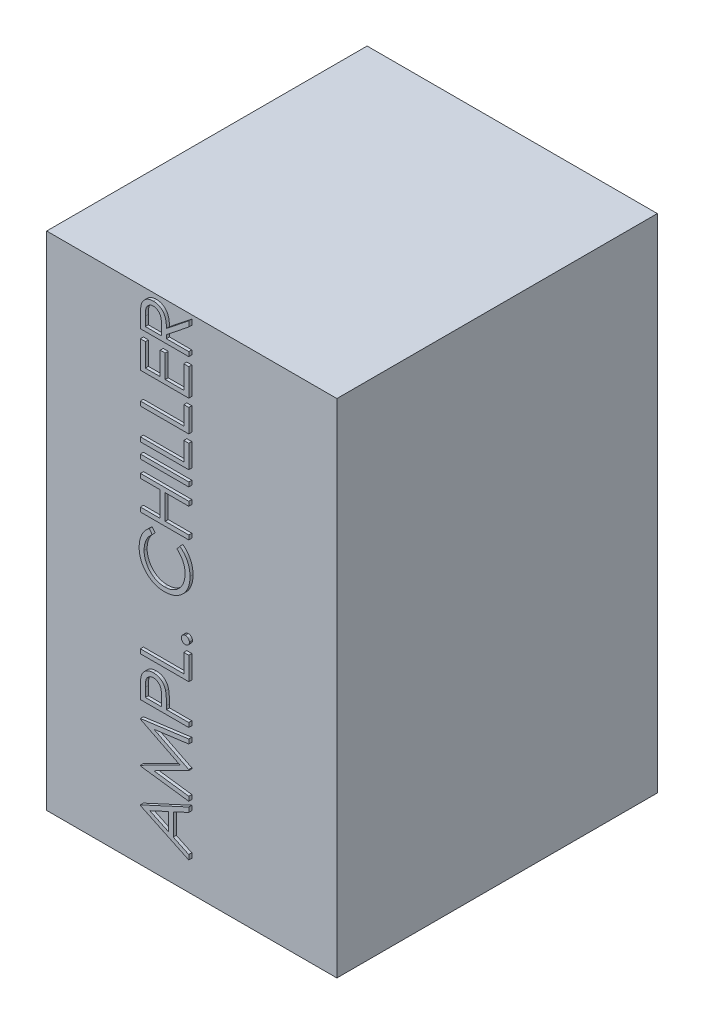
from build123d import *

# Parameters (mm, degrees)
SKETCH1_W           = 480
SKETCH1_H           = 830
BOSS_EXTRUDE1_DEPTH = 530
SKETCH2_W           = 80
SKETCH2_H           = 7.17948718
BOSS_EXTRUDE2_DEPTH = 5


with BuildPart() as part:
    # Sketch1 → Boss-Extrude1 (new body)
    with BuildSketch(Plane.XY):
        with Locations((-240, -415)):
            Rectangle(SKETCH1_W, SKETCH1_H)
    extrude(amount=BOSS_EXTRUDE1_DEPTH)

    # Sketch2 → Boss-Extrude2 (add)
    with BuildSketch(Plane.XY.offset(530)):
        with BuildLine():
            Line((-320, -57.435897436), (-320, -41.426282051))
            add(Edge.make_bspline(
                [(-320, -41.426282051), (-319.996443749, -40.3579134), (-319.989615353, -38.306527242), (-319.951540772, -35.367709633), (-319.842412641, -32.697375988), (-319.748502162, -30.296922518), (-319.577257789, -28.166393261), (-319.413585855, -26.299255187), (-319.199330751, -24.704107815), (-319.000349655, -23.738488357), (-318.91025641, -23.301282051)],
                knots=[0, 0, 0, 0, 0.003205168, 0.006154278, 0.008816272, 0.011222734, 0.01336016, 0.015227474, 0.016845667, 0.018184552, 0.018184552, 0.018184552, 0.018184552], degree=3))
            add(Edge.make_bspline(
                [(-318.91025641, -23.301282051), (-318.765644241, -22.71598824), (-318.479504873, -21.557886524), (-317.874719647, -19.890449841), (-317.174821668, -18.301575366), (-316.352869775, -16.797719143), (-315.402306871, -15.386945141), (-314.341235136, -14.052720272), (-313.171797697, -12.799375486), (-311.883452462, -11.643267931), (-310.503649499, -10.593116346), (-309.036175733, -9.671971657), (-307.487098853, -8.89362133), (-305.854006063, -8.282816107), (-304.154937334, -7.770283409), (-302.372551111, -7.425924576), (-300.512797552, -7.211422669), (-299.247395744, -7.190231989), (-298.605769231, -7.179487179)],
                knots=[0, 0, 0, 0, 0.001807562, 0.003576563, 0.00531274, 0.007012516, 0.008710402, 0.0104098, 0.012121846, 0.013846669, 0.015596696, 0.017317494, 0.019037547, 0.020787573, 0.02254207, 0.024355518, 0.02622613, 0.028150275, 0.028150275, 0.028150275, 0.028150275], degree=3))
            add(Edge.make_bspline(
                [(-298.605769231, -7.179487179), (-297.539823983, -7.213064279), (-295.459888717, -7.278581897), (-292.441354284, -7.88944141), (-289.625598521, -8.890047575), (-287.016166797, -10.26886561), (-284.663923475, -12.02473934), (-282.597855925, -14.13502028), (-280.868943637, -16.600885685), (-279.670022387, -18.896412907), (-278.902184475, -20.924166043), (-278.361924844, -22.593498906), (-277.944508495, -24.414458392), (-277.570562626, -26.369597469), (-277.288238182, -28.467052451), (-277.08145888, -30.701796209), (-276.952223481, -33.075422532), (-276.932977655, -34.706029831), (-276.923076923, -35.544871795)],
                knots=[0, 0, 0, 0, 0.003194896, 0.006234069, 0.009194261, 0.012133557, 0.015053436, 0.017965917, 0.020954087, 0.024057646, 0.025706419, 0.027454977, 0.029316851, 0.03130642, 0.033425504, 0.035662789, 0.038038046, 0.040554531, 0.040554531, 0.040554531, 0.040554531], degree=3))
            Line((-276.923076923, -35.544871795), (-240, -6.153846154))
            Line((-240, -6.153846154), (-240, -15.032051282))
            Line((-240, -15.032051282), (-276.923076923, -44.423076923))
            Line((-276.923076923, -44.423076923), (-276.923076923, -50.256410256))
            Line((-276.923076923, -50.256410256), (-240, -50.256410256))
            Line((-240, -50.256410256), (-240, -57.435897436))
            Line((-240, -57.435897436), (-320, -57.435897436))
        make_face()
        with BuildLine():
            Line((-311.794871795, -50.256410256), (-285.128205128, -50.256410256))
            Line((-285.128205128, -50.256410256), (-285.016025641, -35.608974359))
            add(Edge.make_bspline(
                [(-285.016025641, -35.608974359), (-285.015722913, -34.925087666), (-285.015136139, -33.599520473), (-285.106424834, -31.681792197), (-285.210264007, -29.896185541), (-285.369133228, -28.249553471), (-285.573754598, -26.741083898), (-285.830112569, -25.371781204), (-286.127501219, -24.138593243), (-286.59255894, -22.704997319), (-287.29718131, -21.085240068), (-288.391586443, -19.363403401), (-289.706594721, -17.852629871), (-291.25371258, -16.622217036), (-292.927741254, -15.591331538), (-294.745825914, -14.897586601), (-296.648989665, -14.435235053), (-297.956611379, -14.384687671), (-298.621794872, -14.358974359)],
                knots=[0, 0, 0, 0, 0.002051345, 0.00397609, 0.00575847, 0.007416872, 0.00893762, 0.010323722, 0.011594708, 0.012740065, 0.014842358, 0.016874078, 0.018838445, 0.020820708, 0.022783047, 0.024711459, 0.026635737, 0.028628144, 0.028628144, 0.028628144, 0.028628144], degree=3))
            add(Edge.make_bspline(
                [(-298.621794872, -14.358974359), (-299.26509267, -14.386530718), (-300.539874172, -14.441137365), (-302.40706405, -14.884517988), (-304.169864593, -15.642521506), (-305.830551834, -16.639678493), (-307.314467371, -17.891114771), (-308.597913067, -19.330304061), (-309.648590072, -20.956969405), (-310.346908065, -22.463918264), (-310.756999423, -23.821649035), (-311.055066677, -24.994884128), (-311.261936462, -26.327045895), (-311.457879862, -27.812076075), (-311.616501338, -29.452808767), (-311.725916271, -31.254052804), (-311.789994577, -33.204650062), (-311.793208221, -34.556573809), (-311.794871795, -35.256410256)],
                knots=[0, 0, 0, 0, 0.001928478, 0.00382154, 0.005717516, 0.007666131, 0.009611317, 0.011518435, 0.013429791, 0.015401987, 0.016476542, 0.017681452, 0.01903037, 0.020517218, 0.02217562, 0.023973994, 0.025930173, 0.028029593, 0.028029593, 0.028029593, 0.028029593], degree=3))
            Line((-311.794871795, -35.256410256), (-311.794871795, -50.256410256))
        make_face(mode=Mode.SUBTRACT)
        Polygon((-320, -116.923076923), (-320, -71.794871795), (-311.794871795, -71.794871795), (-311.794871795, -109.743589744), (-287.179487179, -109.743589744), (-287.179487179, -71.794871795), (-278.974358974, -71.794871795), (-278.974358974, -109.743589744), (-248.205128205, -109.743589744), (-248.205128205, -71.794871795), (-240, -71.794871795), (-240, -116.923076923), align=None)
        Polygon((-320, -168.205128205), (-320, -161.025641026), (-248.205128205, -161.025641026), (-248.205128205, -130.256410256), (-240, -130.256410256), (-240, -168.205128205), align=None)
        Polygon((-320, -219.487179487), (-320, -212.307692308), (-248.205128205, -212.307692308), (-248.205128205, -181.538461538), (-240, -181.538461538), (-240, -219.487179487), align=None)
        with Locations((-280, -240.512820513)):
            Rectangle(SKETCH2_W, SKETCH2_H)
        Polygon((-320, -320), (-320, -312.820512821), (-287.179487179, -312.820512821), (-287.179487179, -271.794871795), (-320, -271.794871795), (-320, -264.615384615), (-240, -264.615384615), (-240, -271.794871795), (-278.974358974, -271.794871795), (-278.974358974, -312.820512821), (-240, -312.820512821), (-240, -320), align=None)
        with BuildLine():
            Line((-305.320512821, -336.41025641), (-300.512820513, -342.692307692))
            add(Edge.make_bspline(
                [(-300.512820513, -342.692307692), (-301.046892758, -343.140446879), (-302.107836795, -344.030683364), (-303.597758768, -345.462826188), (-304.993147844, -346.955687734), (-306.302969593, -348.507190873), (-307.474579565, -350.153240976), (-308.599223724, -351.8311189), (-309.583888386, -353.601789386), (-310.78677945, -356.037854833), (-312.014627263, -359.237069865), (-313.070682378, -363.250437682), (-313.736606449, -367.44577068), (-313.809219777, -370.30732071), (-313.846153846, -371.762820513)],
                knots=[0, 0, 0, 0, 0.002091085, 0.004153978, 0.006194842, 0.008220042, 0.010239527, 0.012253026, 0.014276577, 0.016312022, 0.020401168, 0.024529349, 0.028745037, 0.033108988, 0.033108988, 0.033108988, 0.033108988], degree=3))
            add(Edge.make_bspline(
                [(-313.846153846, -371.762820513), (-313.836920417, -372.564724498), (-313.818539255, -374.161090042), (-313.576044964, -376.530198008), (-313.235217307, -378.85506775), (-312.729495628, -381.13418697), (-312.090121498, -383.364654621), (-311.326111963, -385.561052283), (-310.380858757, -387.69158065), (-309.336097489, -389.785710408), (-308.156045454, -391.792097553), (-306.868869193, -393.690479883), (-305.489054917, -395.474044681), (-304.011128839, -397.143796095), (-302.442857912, -398.702938757), (-300.766672325, -400.131853141), (-299.000491023, -401.449630634), (-297.142847282, -402.648760961), (-295.211042188, -403.728256725), (-293.194046298, -404.635944805), (-291.126394657, -405.428713435), (-288.993429074, -406.065893703), (-286.809326352, -406.566315064), (-284.56503836, -406.912283361), (-282.264820149, -407.151967316), (-280.705752846, -407.170264231), (-279.919871795, -407.179487179)],
                knots=[0, 0, 0, 0, 0.002404701, 0.004787084, 0.007137396, 0.009450979, 0.011784347, 0.014095598, 0.016420863, 0.018771612, 0.02111333, 0.023397982, 0.025648258, 0.027873458, 0.030083195, 0.032276836, 0.034475563, 0.036689249, 0.038905775, 0.041107421, 0.043318843, 0.045544562, 0.047779952, 0.050035244, 0.052353817, 0.054710458, 0.054710458, 0.054710458, 0.054710458], degree=3))
            add(Edge.make_bspline(
                [(-279.919871795, -407.179487179), (-278.737467984, -407.150577974), (-276.415974939, -407.093818583), (-273.015129661, -406.590816688), (-269.753990047, -405.820316332), (-266.654636971, -404.684452533), (-263.691233572, -403.25592359), (-260.899717185, -401.473513361), (-258.239191274, -399.401356917), (-255.774092234, -397.018196582), (-253.522381777, -394.403137349), (-251.539502904, -391.597489127), (-249.886593537, -388.608129129), (-248.511142731, -385.468093173), (-247.453846263, -382.153210211), (-246.709523395, -378.669443398), (-246.223987852, -375.024369193), (-246.177503551, -372.533640057), (-246.153846154, -371.266025641)],
                knots=[0, 0, 0, 0, 0.003545291, 0.006960708, 0.010291767, 0.013581867, 0.016842996, 0.020141944, 0.023498388, 0.026943938, 0.030409962, 0.033837876, 0.037231152, 0.040640134, 0.044106714, 0.047649251, 0.051316637, 0.055117452, 0.055117452, 0.055117452, 0.055117452], degree=3))
            add(Edge.make_bspline(
                [(-246.153846154, -371.266025641), (-246.192446834, -369.86939275), (-246.268422206, -367.120485117), (-246.912062186, -363.089215944), (-247.955671737, -359.230112729), (-249.416195675, -355.542967894), (-251.314830827, -352.038175981), (-253.616496597, -348.710252317), (-256.34308706, -345.556387848), (-258.424987134, -343.659901397), (-259.487179487, -342.692307692)],
                knots=[0, 0, 0, 0, 0.004187877, 0.008242745, 0.012211995, 0.016161007, 0.02011184, 0.024143746, 0.028279044, 0.032586634, 0.032586634, 0.032586634, 0.032586634], degree=3))
            Line((-259.487179487, -342.692307692), (-254.727564103, -336.41025641))
            add(Edge.make_bspline(
                [(-254.727564103, -336.41025641), (-254.075279204, -336.915830934), (-252.773833815, -337.924558307), (-250.938717064, -339.557621499), (-249.214161297, -341.279227591), (-247.60877888, -343.093801817), (-246.11592489, -345.004542471), (-244.734788378, -347.011274219), (-243.472699054, -349.112284128), (-242.313408047, -351.290884118), (-241.292691617, -353.552094332), (-240.38818775, -355.87600836), (-239.639358463, -358.276875097), (-239.00593291, -360.734484541), (-238.554271984, -363.27103241), (-238.194604611, -365.857033213), (-237.981223278, -368.516691013), (-237.959650259, -370.309451934), (-237.948717949, -371.217948718)],
                knots=[0, 0, 0, 0, 0.002475274, 0.004938692, 0.007363706, 0.009781879, 0.012202228, 0.014633746, 0.017085303, 0.019551378, 0.022032869, 0.024523864, 0.027027662, 0.029573521, 0.032132109, 0.034752093, 0.037404518, 0.040129631, 0.040129631, 0.040129631, 0.040129631], degree=3))
            add(Edge.make_bspline(
                [(-237.948717949, -371.217948718), (-237.95470635, -372.078375394), (-237.966547672, -373.779762596), (-238.158368641, -376.291734061), (-238.420076914, -378.737210194), (-238.814137052, -381.109201642), (-239.279150539, -383.4206525), (-239.902493548, -385.650608717), (-240.600760213, -387.821013526), (-241.421445624, -389.923147027), (-242.347529796, -391.958797308), (-243.394194, -393.921398711), (-244.552636621, -395.810048594), (-245.797322573, -397.643315357), (-247.16823233, -399.394117269), (-248.646326833, -401.07762642), (-250.226624222, -402.70328302), (-251.366163727, -403.709058677), (-251.939102564, -404.21474359)],
                knots=[0, 0, 0, 0, 0.002580576, 0.00510277, 0.007553855, 0.009956632, 0.012313873, 0.014623178, 0.01689865, 0.019151493, 0.02138895, 0.023604259, 0.025819511, 0.028033138, 0.030248274, 0.032485502, 0.034751983, 0.037043818, 0.037043818, 0.037043818, 0.037043818], degree=3))
            add(Edge.make_bspline(
                [(-251.939102564, -404.21474359), (-252.934350271, -405.024648326), (-254.91283018, -406.634679919), (-258.119064604, -408.695473369), (-261.463664114, -410.453619957), (-264.96600121, -411.891014641), (-268.627437419, -412.995101449), (-272.442082559, -413.771346248), (-276.402310954, -414.27225583), (-279.095685305, -414.32974982), (-280.46474359, -414.358974359)],
                knots=[0, 0, 0, 0, 0.003846988, 0.007647533, 0.01141083, 0.015169517, 0.018987019, 0.022865422, 0.026836937, 0.03094263, 0.03094263, 0.03094263, 0.03094263], degree=3))
            add(Edge.make_bspline(
                [(-280.46474359, -414.358974359), (-281.903725385, -414.323427078), (-284.734832232, -414.253490021), (-288.88966545, -413.65930041), (-292.870268853, -412.703442211), (-296.669211586, -411.345799044), (-300.306475134, -409.624533871), (-303.754274102, -407.498211269), (-307.034658094, -404.991533732), (-310.09785241, -402.124160757), (-312.898751898, -398.979764521), (-315.362893698, -395.612477347), (-317.413579778, -392.028889987), (-319.127777776, -388.268481949), (-320.445365505, -384.303094942), (-321.367724058, -380.141189362), (-321.941829573, -375.790585595), (-322.014405754, -372.82230158), (-322.051282051, -371.314102564)],
                knots=[0, 0, 0, 0, 0.004315185, 0.008489856, 0.012563302, 0.016577781, 0.020570514, 0.024613584, 0.028706684, 0.032936027, 0.037181461, 0.041322934, 0.045429628, 0.04954644, 0.053701997, 0.057939802, 0.062318821, 0.066842142, 0.066842142, 0.066842142, 0.066842142], degree=3))
            add(Edge.make_bspline(
                [(-322.051282051, -371.314102564), (-322.040252166, -370.394917649), (-322.018419619, -368.575483678), (-321.805846721, -365.883950778), (-321.450739265, -363.263715405), (-320.969947086, -360.712021852), (-320.364486341, -358.221492993), (-319.609888309, -355.796788206), (-318.711486328, -353.443844975), (-317.685552908, -351.163427698), (-316.531896647, -348.970930448), (-315.264125263, -346.867729638), (-313.888644466, -344.862210161), (-312.391372455, -342.964795851), (-310.784728921, -341.173165255), (-309.087533465, -339.460741194), (-307.256234741, -337.877370682), (-305.966934611, -336.900189713), (-305.320512821, -336.41025641)],
                knots=[0, 0, 0, 0, 0.002757156, 0.005457512, 0.008093376, 0.010686412, 0.013243946, 0.015778329, 0.01829925, 0.020795343, 0.023275592, 0.025727149, 0.028158667, 0.030566409, 0.032972605, 0.035374955, 0.037794614, 0.040227611, 0.040227611, 0.040227611, 0.040227611], degree=3))
        make_face()
        with BuildLine():
            add(Edge.make_bspline(
                [(-252.307692308, -466.153846154), (-252.281219926, -465.70835559), (-252.229323917, -464.835023421), (-251.87328566, -463.572414774), (-251.241087706, -462.429679695), (-250.398509915, -461.411799814), (-249.376894758, -460.572794636), (-248.243273987, -459.918066587), (-246.970094728, -459.565129782), (-246.091702157, -459.513611798), (-245.641025641, -459.487179487)],
                knots=[0, 0, 0, 0, 0.001336292, 0.002619645, 0.003896075, 0.005227747, 0.006559419, 0.007843572, 0.009126925, 0.01047917, 0.01047917, 0.01047917, 0.01047917], degree=3))
            add(Edge.make_bspline(
                [(-245.641025641, -459.487179487), (-245.201102594, -459.514423333), (-244.333580805, -459.568147796), (-243.071097552, -459.918225827), (-241.93617664, -460.571999834), (-240.916956071, -461.417137991), (-240.054027143, -462.423592458), (-239.430210709, -463.575989935), (-239.047454964, -464.831830585), (-238.999022347, -465.707783888), (-238.974358974, -466.153846154)],
                knots=[0, 0, 0, 0, 0.001320342, 0.002603694, 0.003887847, 0.005219519, 0.006561469, 0.007837899, 0.009125747, 0.010462039, 0.010462039, 0.010462039, 0.010462039], degree=3))
            add(Edge.make_bspline(
                [(-238.974358974, -466.153846154), (-238.998127053, -466.600229671), (-239.044528568, -467.471687227), (-239.438034017, -468.722845812), (-240.048074427, -469.882267195), (-240.918526986, -470.888460122), (-241.930904606, -471.740446965), (-243.078913645, -472.365215899), (-244.3299627, -472.745647166), (-245.200389914, -472.79535119), (-245.641025641, -472.820512821)],
                knots=[0, 0, 0, 0, 0.001336292, 0.002608793, 0.00389933, 0.00524128, 0.006572952, 0.007849382, 0.009137229, 0.010457571, 0.010457571, 0.010457571, 0.010457571], degree=3))
            add(Edge.make_bspline(
                [(-245.641025641, -472.820512821), (-246.092440033, -472.796236266), (-246.973771233, -472.748839273), (-248.235465118, -472.36539561), (-249.382172301, -471.739653624), (-250.396951275, -470.893816024), (-251.246946765, -469.876117832), (-251.865570608, -468.726490285), (-252.232208601, -467.46844365), (-252.282094698, -466.599645057), (-252.307692308, -466.153846154)],
                knots=[0, 0, 0, 0, 0.001352245, 0.002640093, 0.003916523, 0.005248194, 0.006579866, 0.007870403, 0.009138355, 0.010474647, 0.010474647, 0.010474647, 0.010474647], degree=3))
        make_face()
        Polygon((-320, -523.076923077), (-320, -515.897435897), (-248.205128205, -515.897435897), (-248.205128205, -485.128205128), (-240, -485.128205128), (-240, -523.076923077), align=None)
        with BuildLine():
            Line((-320, -588.717948718), (-320, -573.028846154))
            add(Edge.make_bspline(
                [(-320, -573.028846154), (-319.9988138, -571.949739728), (-319.996540989, -569.882123892), (-319.927632513, -566.917208333), (-319.835593836, -564.224414467), (-319.708007706, -561.809548617), (-319.557228501, -559.665180661), (-319.345753315, -557.801013814), (-319.124946559, -556.202395384), (-318.900457267, -555.244533682), (-318.798076923, -554.807692308)],
                knots=[0, 0, 0, 0, 0.003237219, 0.006202656, 0.00889668, 0.011319945, 0.013457372, 0.01534391, 0.016948557, 0.018293947, 0.018293947, 0.018293947, 0.018293947], degree=3))
            add(Edge.make_bspline(
                [(-318.798076923, -554.807692308), (-318.646712148, -554.254702073), (-318.347549318, -553.161752126), (-317.748464188, -551.586801352), (-317.037696585, -550.088686816), (-316.229182544, -548.66072201), (-315.283123271, -547.328915057), (-314.262456077, -546.048869431), (-313.101221107, -544.86577066), (-311.836044069, -543.76359382), (-310.482971326, -542.744882344), (-309.017419274, -541.888980505), (-307.483142611, -541.140606594), (-305.859289247, -540.527874896), (-304.144282639, -540.072222148), (-302.350310695, -539.73394589), (-300.475356182, -539.518248458), (-299.193970539, -539.497660182), (-298.541666667, -539.487179487)],
                knots=[0, 0, 0, 0, 0.001719231, 0.00339795, 0.005046723, 0.006690582, 0.008313292, 0.009942636, 0.011597239, 0.013278176, 0.014973716, 0.016669483, 0.018361004, 0.020090363, 0.02186697, 0.023677371, 0.02556391, 0.027520089, 0.027520089, 0.027520089, 0.027520089], degree=3))
            add(Edge.make_bspline(
                [(-298.541666667, -539.487179487), (-297.883888912, -539.496812052), (-296.596902307, -539.515658817), (-294.71409572, -539.741859624), (-292.914818231, -540.046549719), (-291.203059363, -540.515053772), (-289.58898461, -541.128669157), (-288.047927878, -541.848487508), (-286.606106806, -542.716682487), (-285.258286976, -543.714278595), (-284.003203266, -544.824029324), (-282.849950821, -546.041239339), (-281.805280228, -547.360994596), (-280.866849515, -548.779100838), (-280.05642027, -550.309383097), (-279.330539014, -551.928632321), (-278.720914771, -553.650922982), (-278.400227653, -554.842751873), (-278.237179487, -555.448717949)],
                knots=[0, 0, 0, 0, 0.001972196, 0.003858734, 0.005681999, 0.007443143, 0.009172502, 0.010857101, 0.012539107, 0.014212233, 0.015881132, 0.017558857, 0.019235739, 0.020924754, 0.022652701, 0.024424676, 0.026244345, 0.028126454, 0.028126454, 0.028126454, 0.028126454], degree=3))
            add(Edge.make_bspline(
                [(-278.237179487, -555.448717949), (-278.130676495, -555.949919861), (-277.897268996, -557.048332993), (-277.634925502, -558.857196075), (-277.419775173, -560.964318871), (-277.218995163, -563.362532015), (-277.112606859, -566.057428087), (-276.987689637, -569.042826285), (-276.928748026, -572.328830202), (-276.925022184, -574.620715486), (-276.923076923, -575.817307692)],
                knots=[0, 0, 0, 0, 0.001536875, 0.003368151, 0.005479464, 0.00789099, 0.010586349, 0.013569228, 0.01685511, 0.020444889, 0.020444889, 0.020444889, 0.020444889], degree=3))
            Line((-276.923076923, -575.817307692), (-276.923076923, -581.538461538))
            Line((-276.923076923, -581.538461538), (-240, -581.538461538))
            Line((-240, -581.538461538), (-240, -588.717948718))
            Line((-240, -588.717948718), (-320, -588.717948718))
        make_face()
        with BuildLine():
            Line((-311.794871795, -581.538461538), (-285.128205128, -581.538461538))
            Line((-285.128205128, -581.538461538), (-284.951923077, -567.532051282))
            add(Edge.make_bspline(
                [(-284.951923077, -567.532051282), (-284.951546494, -566.848162481), (-284.950819509, -565.527929252), (-285.042219697, -563.62087954), (-285.14632487, -561.851307341), (-285.303777899, -560.225866989), (-285.510173888, -558.738855128), (-285.766847943, -557.403115907), (-286.045893469, -556.198671182), (-286.512109317, -554.81319085), (-287.228964026, -553.255865311), (-288.272505976, -551.55460603), (-289.624364731, -550.123973503), (-291.140084212, -548.888244101), (-292.821718624, -547.88831162), (-294.630431273, -547.182899148), (-296.539426269, -546.748535265), (-297.844915765, -546.694287379), (-298.509615385, -546.666666667)],
                knots=[0, 0, 0, 0, 0.002051345, 0.003960079, 0.005726465, 0.007368917, 0.008857923, 0.010228279, 0.011448755, 0.012563661, 0.01460748, 0.016581433, 0.0185208, 0.020480521, 0.022434664, 0.024363075, 0.026283813, 0.02827622, 0.02827622, 0.02827622, 0.02827622], degree=3))
            add(Edge.make_bspline(
                [(-298.509615385, -546.666666667), (-299.152780778, -546.695527444), (-300.431313978, -546.752899097), (-302.305123492, -547.179314609), (-304.093332795, -547.895886441), (-305.761424763, -548.889118297), (-307.273809047, -550.094858461), (-308.589849024, -551.495158561), (-309.640738591, -553.093600999), (-310.345152944, -554.568126329), (-310.757562675, -555.888545621), (-311.055431201, -557.029798416), (-311.260832082, -558.324986871), (-311.457375106, -559.761804727), (-311.616024548, -561.338427735), (-311.726196778, -563.064876531), (-311.789998208, -564.935401877), (-311.793207935, -566.233923113), (-311.794871795, -566.907051282)],
                knots=[0, 0, 0, 0, 0.001928478, 0.003833576, 0.005732191, 0.007686334, 0.009636003, 0.011518317, 0.013425099, 0.015353644, 0.01639765, 0.017571467, 0.01888879, 0.020327978, 0.02192259, 0.023640999, 0.025517094, 0.027536389, 0.027536389, 0.027536389, 0.027536389], degree=3))
            Line((-311.794871795, -566.907051282), (-311.794871795, -581.538461538))
        make_face(mode=Mode.SUBTRACT)
        Polygon((-240, -694.358974359), (-320, -683.798076923), (-320, -682.772435897), (-254.358974359, -649.743589744), (-320, -616.794871795), (-320, -615.753205128), (-240, -605.128205128), (-240, -612.33974359), (-297.564102564, -620), (-240, -648.878205128), (-240, -650.496794872), (-297.692307692, -679.487179487), (-240, -687.131410256), align=None)
        Polygon((-320, -739.487179487), (-240, -702.564102564), (-240, -710.368589744), (-265.641025641, -722.195512821), (-265.641025641, -758.461538462), (-240, -770.625), (-240, -778.461538462), (-320, -740.512820513), align=None)
        Polygon((-304.407051282, -740.080128205), (-273.846153846, -754.567307692), (-273.846153846, -725.977564103), align=None, mode=Mode.SUBTRACT)
    extrude(amount=BOSS_EXTRUDE2_DEPTH)


solid = part.part
